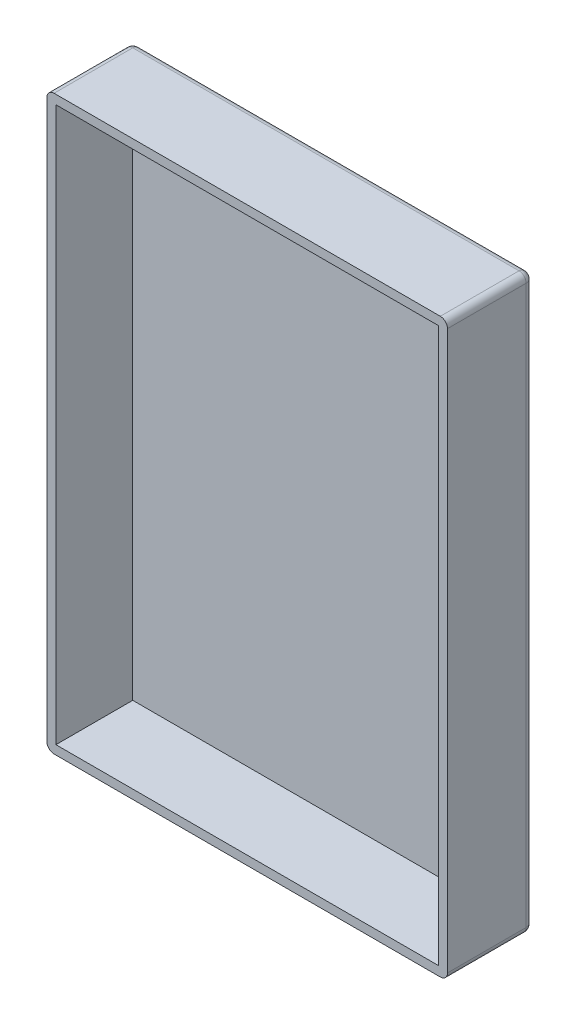
from build123d import *

# Parameters (mm, degrees)
SKETCH1_W           = 88.9
SKETCH1_H           = 127
BOSS_EXTRUDE1_DEPTH = 19.05
FILLET1_R           = 1.5875
SHELL1_T            = -2


with BuildPart() as part:
    # Sketch1 → Boss-Extrude1 (new body)
    with BuildSketch(Plane.XY):
        Rectangle(SKETCH1_W, SKETCH1_H)
    extrude(amount=BOSS_EXTRUDE1_DEPTH)

    # Fillet1
    fillet1_edges = [part.edges().sort_by_distance(p)[0] for p in [
        (-44.45, 0, 0),
        (0, 63.5, 0),
        (44.45, 0, 0),
        (0, -63.5, 0),
        (-44.45, -63.5, 9.525),
        (-44.45, 63.5, 9.525),
        (44.45, 63.5, 9.525),
        (44.45, -63.5, 9.525),
    ]]
    fillet(fillet1_edges, radius=FILLET1_R)

    # Shell1
    shell1_openings = [part.faces().sort_by_distance(p)[0] for p in [
        (0, 0, 19.05),
    ]]
    offset(amount=SHELL1_T, openings=shell1_openings, kind=Kind.INTERSECTION)


solid = part.part
